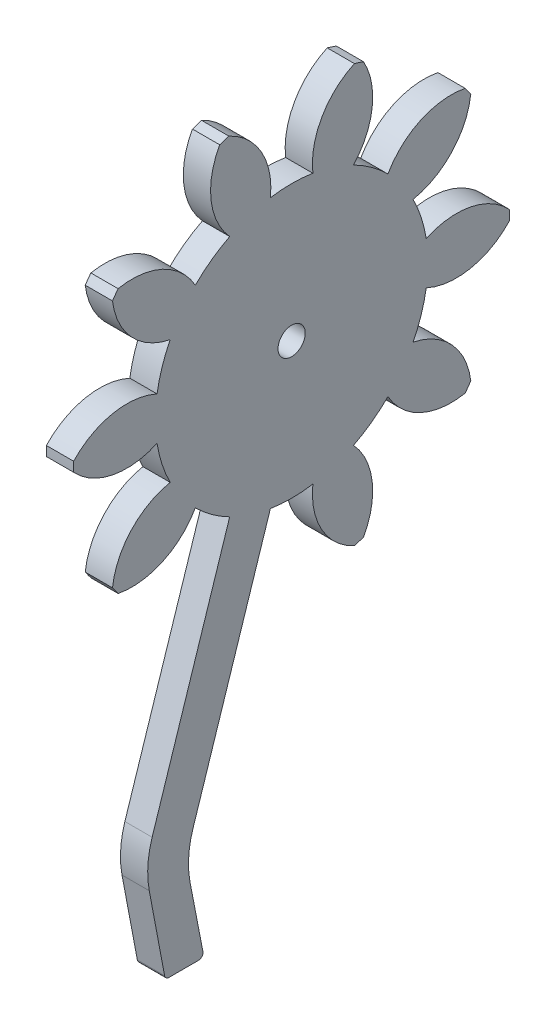
from build123d import *

# Parameters (mm, degrees)
BASPROSKE_W         = 3
BASPROSKE_H         = 24
TOOTHCUT_DEPTH      = 35.073450075
TEETHCUTS_COUNT     = 10
TEETHCUTS_ANGLE     = 324
BORSKE_R            = 1.5
BORE_DEPTH          = 50.0000508
CUT_EXTRUDE1_DEPTH  = 10
BOSS_EXTRUDE1_DEPTH = 3
FILLET1_R           = 10
FILLET2_R           = 0.5


with BuildPart() as part:
    # BasProSke → Base-Revolve (revolve)
    with BuildSketch(Plane(origin=(0, 0, 0), x_dir=(1, 0, 0), z_dir=(0, 1, 0)), mode=Mode.PRIVATE) as base_revolve_sk:
        with Locations((1.5, 12)):
            Rectangle(BASPROSKE_W, BASPROSKE_H)
    revolve(base_revolve_sk.sketch.rotate(Axis((-10, 0, 0), (1, 0, 0)), 180), axis=Axis((-10, 0, 0), (1, 0, 0)))

    # TooCutSke → ToothCut (cut, through all)
    with BuildSketch(Plane(origin=(0, 0, 0), x_dir=(0, 0, -1), z_dir=(1, 0, 0))):
        with BuildLine():
            ThreePointArc((2.33803632, 14.815653451), (0, 14.999), (-2.33803632, 14.815653451))
            ThreePointArc((-2.33803632, 14.815653451), (-3.315013319, 19.654913653), (-6.946609122, 22.999227528))
            ThreePointArc((-6.946609122, 22.999227528), (0, 24.0254), (6.946609122, 22.999227528))
            ThreePointArc((6.946609122, 22.999227528), (3.315013319, 19.654913653), (2.33803632, 14.815653451))
        make_face()
    toothcut = extrude(amount=TOOTHCUT_DEPTH, mode=Mode.SUBTRACT)

    # TeethCuts: ToothCut ×10 about axis
    teethcuts_axis = Axis((-10, 0, 0), (1, 0, 0))
    for i in range(1, TEETHCUTS_COUNT):
        add(toothcut.rotate(teethcuts_axis, i * TEETHCUTS_ANGLE / (TEETHCUTS_COUNT - 1)), mode=Mode.SUBTRACT)

    # BorSke → Bore (cut, symmetric)
    with BuildSketch(Plane(origin=(0, 0, 0), x_dir=(0, 0, -1), z_dir=(1, 0, 0))):
        with Locations(Location((0, 0, 0), (0, 0, 180))):
            Circle(BORSKE_R)
    extrude(amount=BORE_DEPTH, both=True, mode=Mode.SUBTRACT)

    # Sketch1 → Cut-Extrude1 (cut)
    with BuildSketch(Plane.ZY):
        Polygon((6.816911485, -13.360378693), (2.33803632, -14.815653451), (0, -15.575327501), (3.846423881, -27.413402957), (12.603452521, -24.568071871), (8.75702864, -12.729996416), align=None)
    extrude(amount=-CUT_EXTRUDE1_DEPTH, mode=Mode.SUBTRACT)

    # Sketch2 → Boss-Extrude1 (add)
    with BuildSketch(Plane.ZY):
        Polygon((11.666327165, -43.525180612), (16.145202329, -42.069905854), (6.816911485, -13.360378693), (2.33803632, -14.815653451), align=None)
        Polygon((13.905764747, -53.929068958), (9.648574383, -53.929068958), (11.666327165, -43.525180612), (16.145202329, -42.069905854), align=None)
    extrude(amount=-BOSS_EXTRUDE1_DEPTH)

    # Fillet1
    fillet1_edges = [part.edges().sort_by_distance(p)[0] for p in [
        (1.5, -43.525180612, 11.666327165),
        (1.5, -42.069905854, 16.145202329),
    ]]
    fillet(fillet1_edges, radius=FILLET1_R)

    # Fillet2
    fillet2_edges = [part.edges().sort_by_distance(p)[0] for p in [
        (1.5, -53.929068958, 13.905764747),
        (1.5, -53.929068958, 9.648574383),
    ]]
    fillet(fillet2_edges, radius=FILLET2_R)


solid = part.part
